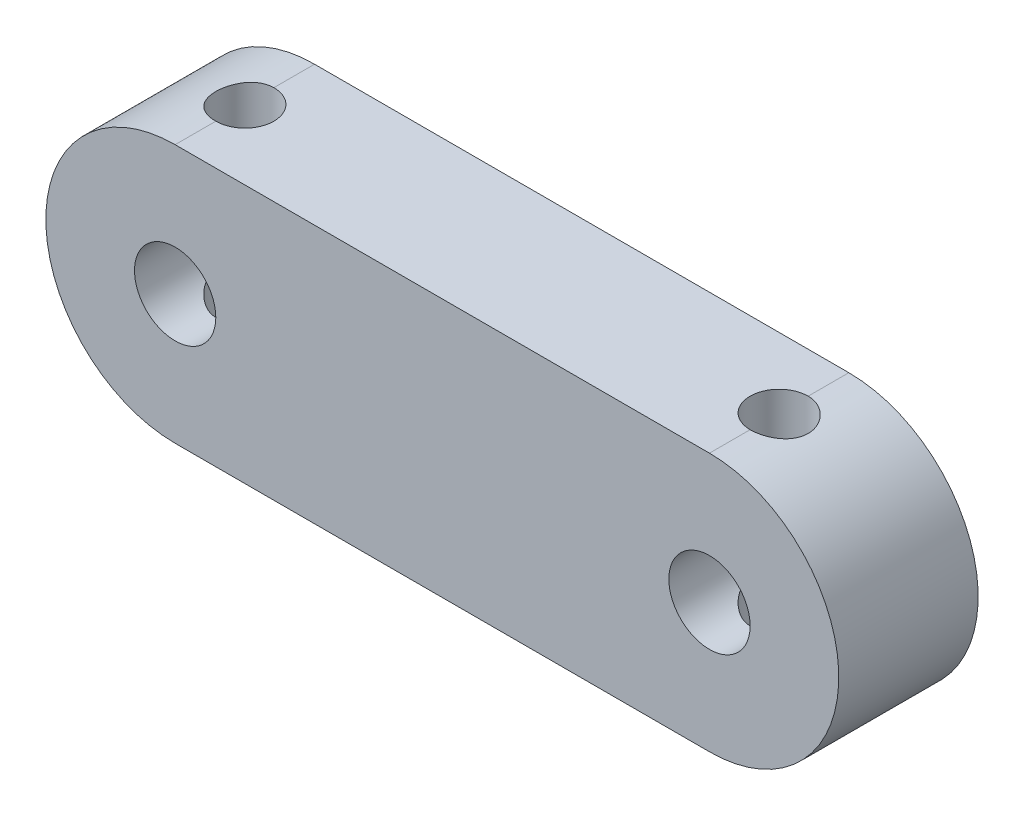
from build123d import *

# Parameters (mm, degrees)
SKETCH1_R               = 1.75
BOSS_EXTRUDE1_DEPTH     = 6
SKETCH2_R               = 1.25
CUT_EXTRUDE1_DEPTH      = 6.566489362
CUT_EXTRUDE1_DEPTH_BACK = 6.566489362


with BuildPart() as part:
    # Sketch1 → Boss-Extrude1 (new body)
    with BuildSketch(Plane.XY):
        with BuildLine():
            Line((-4.465425532, 5.566489362), (18.534574468, 5.566489362))
            ThreePointArc((18.534574468, 5.566489362), (24.10106383, 0), (18.534574468, -5.566489362))
            Line((18.534574468, -5.566489362), (-4.465425532, -5.566489362))
            ThreePointArc((-4.465425532, -5.566489362), (-10.031914894, 0), (-4.465425532, 5.566489362))
        make_face()
        with Locations((-4.465425532, 0)):
            Circle(SKETCH1_R, mode=Mode.SUBTRACT)
        with Locations((18.534574468, 0)):
            Circle(SKETCH1_R, mode=Mode.SUBTRACT)
    extrude(amount=BOSS_EXTRUDE1_DEPTH)

    # Sketch2 → Cut-Extrude1 (cut, two sides)
    with BuildSketch(Plane(origin=(0, 0, 0), x_dir=(1, 0, 0), z_dir=(0, 1, 0))) as cut_extrude1_sk:
        with Locations((18.534574468, -3)):
            Circle(SKETCH2_R)
        with Locations((-4.465425532, -3)):
            Circle(SKETCH2_R)
    extrude(amount=CUT_EXTRUDE1_DEPTH, mode=Mode.SUBTRACT)
    extrude(cut_extrude1_sk.sketch, amount=-CUT_EXTRUDE1_DEPTH_BACK, mode=Mode.SUBTRACT)


solid = part.part
